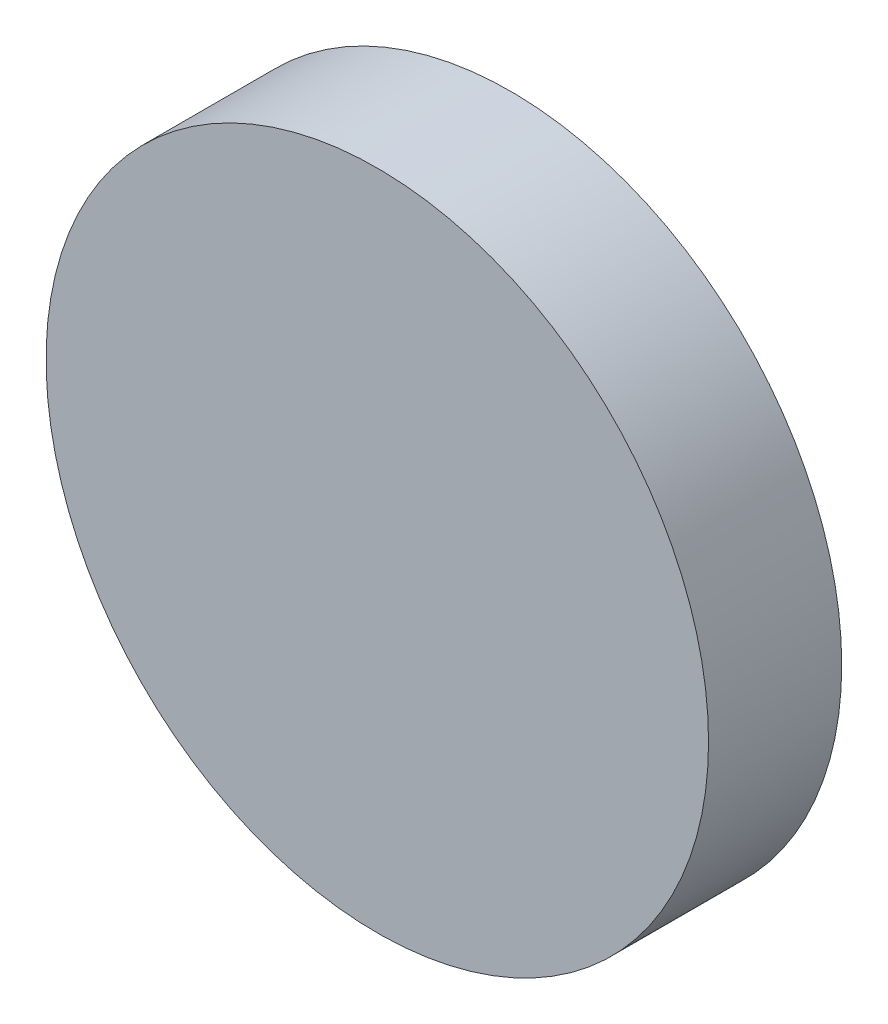
from build123d import *

# Parameters (mm, degrees)
SKETCH1_R      = 60.6425
EXTRUDE1_DEPTH = 24.384


with BuildPart() as part:
    # Sketch1 → Extrude1 (new body)
    with BuildSketch(Plane.XY):
        Circle(SKETCH1_R)
    extrude(amount=EXTRUDE1_DEPTH)


solid = part.part
